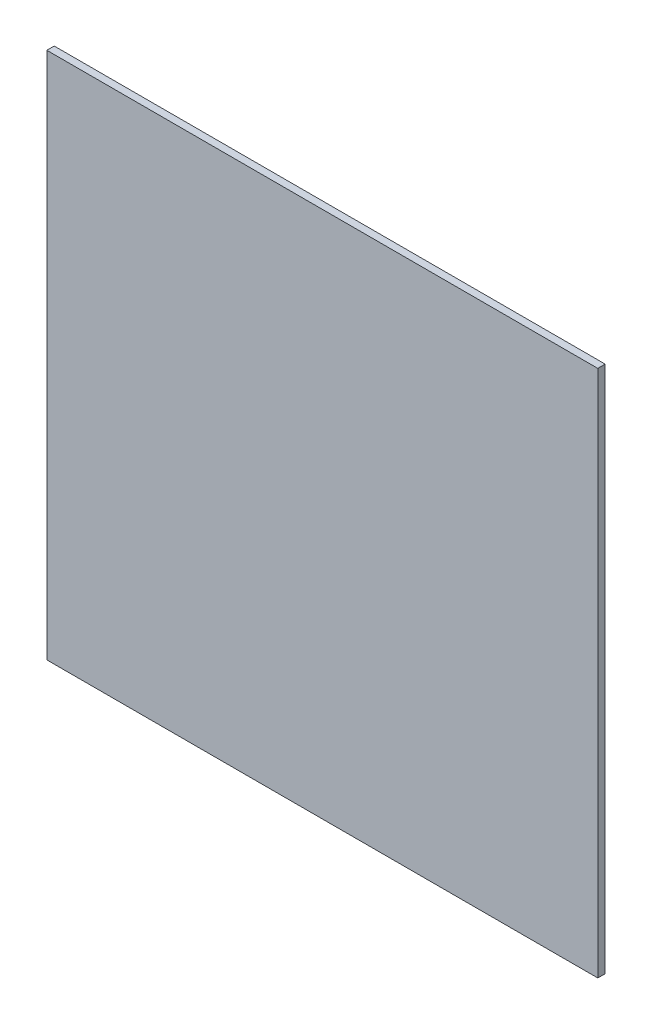
from build123d import *

# Parameters (mm, degrees)
SKETCH1_W           = 323.85
SKETCH1_H           = 310.3372
BOSS_EXTRUDE1_DEPTH = 4.3434


with BuildPart() as part:
    # Sketch1 → Boss-Extrude1 (new body)
    with BuildSketch(Plane.XY):
        Rectangle(SKETCH1_W, SKETCH1_H)
    extrude(amount=BOSS_EXTRUDE1_DEPTH)


solid = part.part
